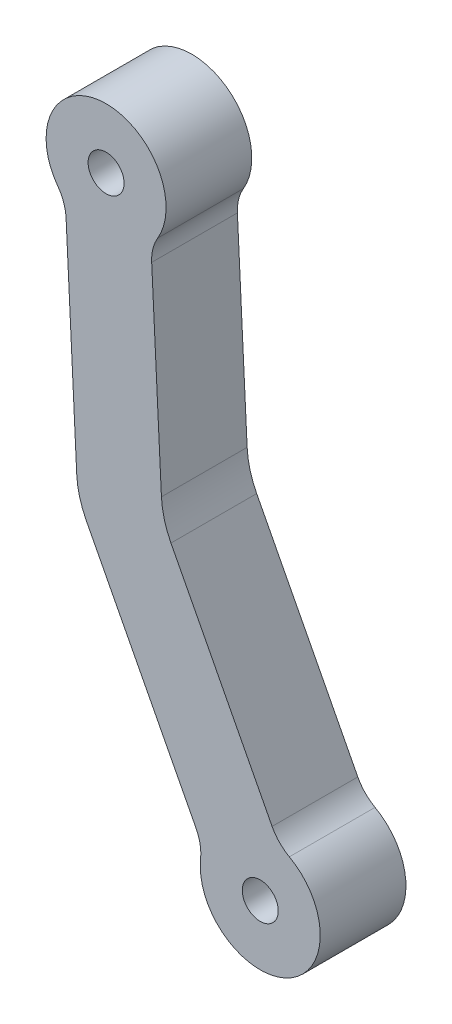
from build123d import *

# Parameters (mm, degrees)
CROQUIS1_R              = 2.1
SALIENTE_EXTRUIR1_DEPTH = 10


with BuildPart() as part:
    # Croquis1 → Saliente-Extruir1 (new body)
    with BuildSketch(Plane.XY):
        with BuildLine():
            Line((-43.685266481, -9.509101851), (-55.484948694, 13.222697812))
            ThreePointArc((-55.484948694, 13.222697812), (-56.263095716, 15.220767285), (-56.597387965, 17.338795401))
            Line((-56.597387965, 17.338795401), (-57.734092582, 40.460761941))
            ThreePointArc((-57.734092582, 40.460761941), (-57.592357435, 41.912848633), (-57.037475041, 43.262200381))
            ThreePointArc((-57.037475041, 43.262200381), (-63.397480334, 53.832057006), (-68.690069236, 42.689344629))
            ThreePointArc((-68.690069236, 42.689344629), (-68.005510605, 41.40092523), (-67.722030303, 39.969742507))
            Line((-67.722030303, 39.969742507), (-66.478182752, 14.668357223))
            ThreePointArc((-66.478182752, 14.668357223), (-66.143890502, 12.550329107), (-65.365743481, 10.552259633))
            Line((-65.365743481, 10.552259633), (-52.560764931, -14.116218874))
            ThreePointArc((-52.560764931, -14.116218874), (-52.084712706, -15.495355776), (-52.027049902, -16.95320327))
            ThreePointArc((-52.027049902, -16.95320327), (-41.842018175, -23.912848963), (-41.672301733, -11.578233615))
            ThreePointArc((-41.672301733, -11.578233615), (-42.831358598, -10.692100558), (-43.685266481, -9.509101851))
        make_face()
        with Locations((-45.067, -17.7)):
            Circle(CROQUIS1_R, mode=Mode.SUBTRACT)
        with Locations((-63.053766888, 46.840500594)):
            Circle(CROQUIS1_R, mode=Mode.SUBTRACT)
    extrude(amount=SALIENTE_EXTRUIR1_DEPTH)


solid = part.part
